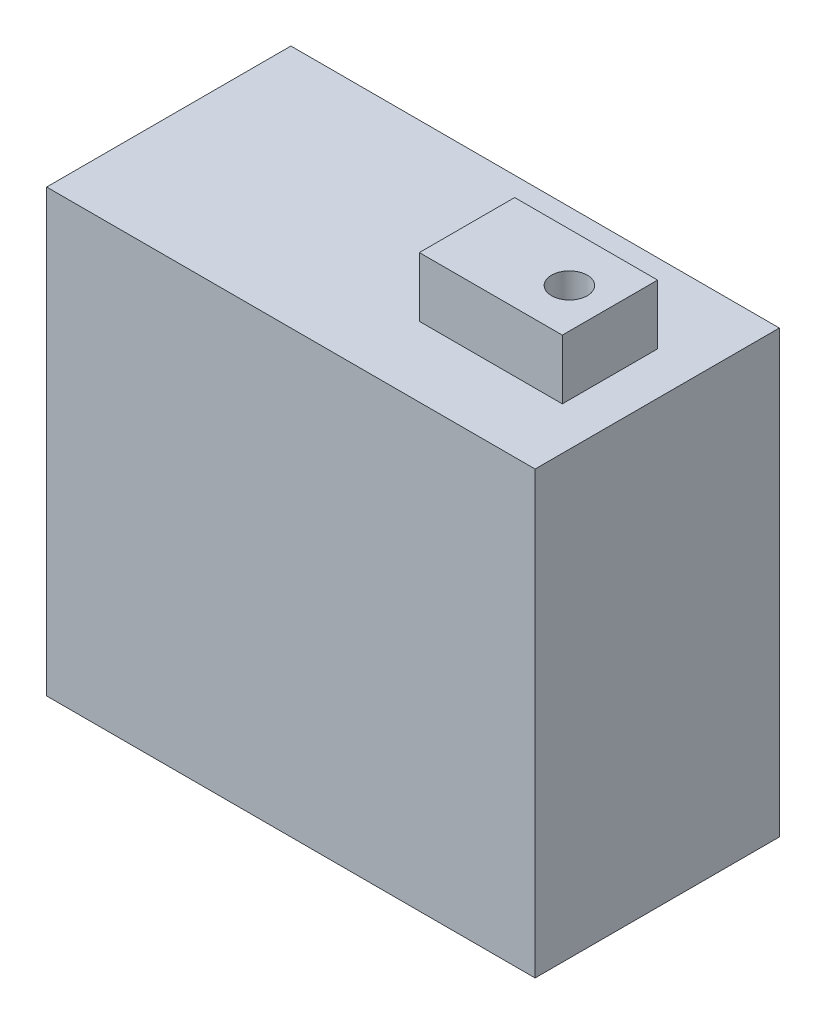
from build123d import *

# Parameters (mm, degrees)
SKETCH3_W           = 41
SKETCH3_H           = 20.5
BOSS_EXTRUDE1_DEPTH = 37
SKETCH5_W           = 12
SKETCH5_H           = 8
BOSS_EXTRUDE2_DEPTH = 5
SKETCH6_R           = 1.5
CUT_EXTRUDE1_DEPTH  = 30


with BuildPart() as part:
    # Sketch3 → Boss-Extrude1 (new body)
    with BuildSketch(Plane(origin=(0, 0, 0), x_dir=(1, 0, 0), z_dir=(0, 1, 0))):
        with Locations((20.5, 10.25)):
            Rectangle(SKETCH3_W, SKETCH3_H)
    extrude(amount=BOSS_EXTRUDE1_DEPTH)

    # Sketch5 → Boss-Extrude2 (add)
    with BuildSketch(Plane(origin=(0, 37, 0), x_dir=(1, 0, 0), z_dir=(0, 1, 0))):
        with Locations((31.406806077, 9.876249369)):
            Rectangle(SKETCH5_W, SKETCH5_H)
    extrude(amount=BOSS_EXTRUDE2_DEPTH)

    # Sketch6 → Cut-Extrude1 (cut)
    with BuildSketch(Plane(origin=(0, 42, 0), x_dir=(1, 0, 0), z_dir=(0, 1, 0))):
        with Locations((34.09544318, 9.783255032)):
            Circle(SKETCH6_R)
    extrude(amount=-CUT_EXTRUDE1_DEPTH, mode=Mode.SUBTRACT)


solid = part.part
